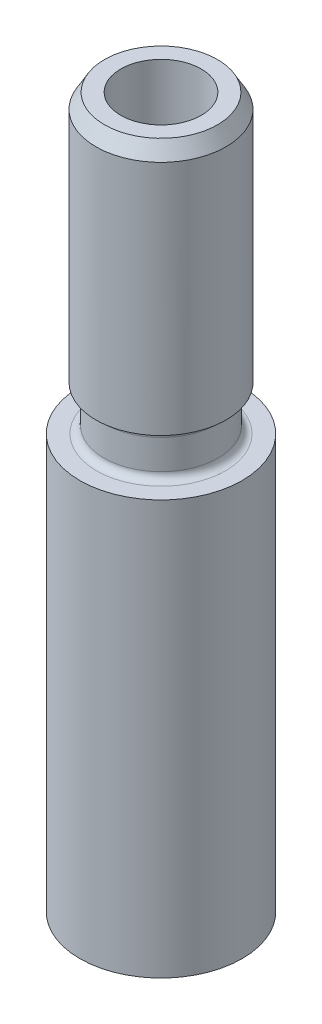
from build123d import *

# Parameters (mm, degrees)
CHAMFER1_SIZE  = 0.79375
CHAMFER1_SIZE2 = 0.458271776
FILLET1_R      = 0.396875


with BuildPart() as part:
    # Sketch1 → Revolve1 (revolve)
    with BuildSketch(Plane.XY):
        Polygon((0, 0), (4.3561, 0), (4.3561, 22.225), (3.0607, 22.225), (3.0607, 24.60625), (3.4925, 24.60625), (3.4925, 38.1), (2.159, 38.1), (2.159, 2.273235175), (0, 2.273235175), align=None)
    revolve(axis=Axis((0, 0, 0), (0, 1, 0)))

    # Chamfer1
    chamfer1_edges = [part.edges().sort_by_distance(p)[0] for p in [
        (-3.4925, 38.1, 0),
    ]]
    chamfer1_side = [part.faces().sort_by_distance(p)[0] for p in [
        (-3.4925, 31.353125, 0),
    ]]
    chamfer(chamfer1_edges, length=CHAMFER1_SIZE, length2=CHAMFER1_SIZE2, reference=chamfer1_side[0])

    # Fillet1
    fillet1_edges = [part.edges().sort_by_distance(p)[0] for p in [
        (-3.0607, 24.60625, 0),
        (-3.0607, 22.225, 0),
    ]]
    fillet(fillet1_edges, radius=FILLET1_R)


solid = part.part
